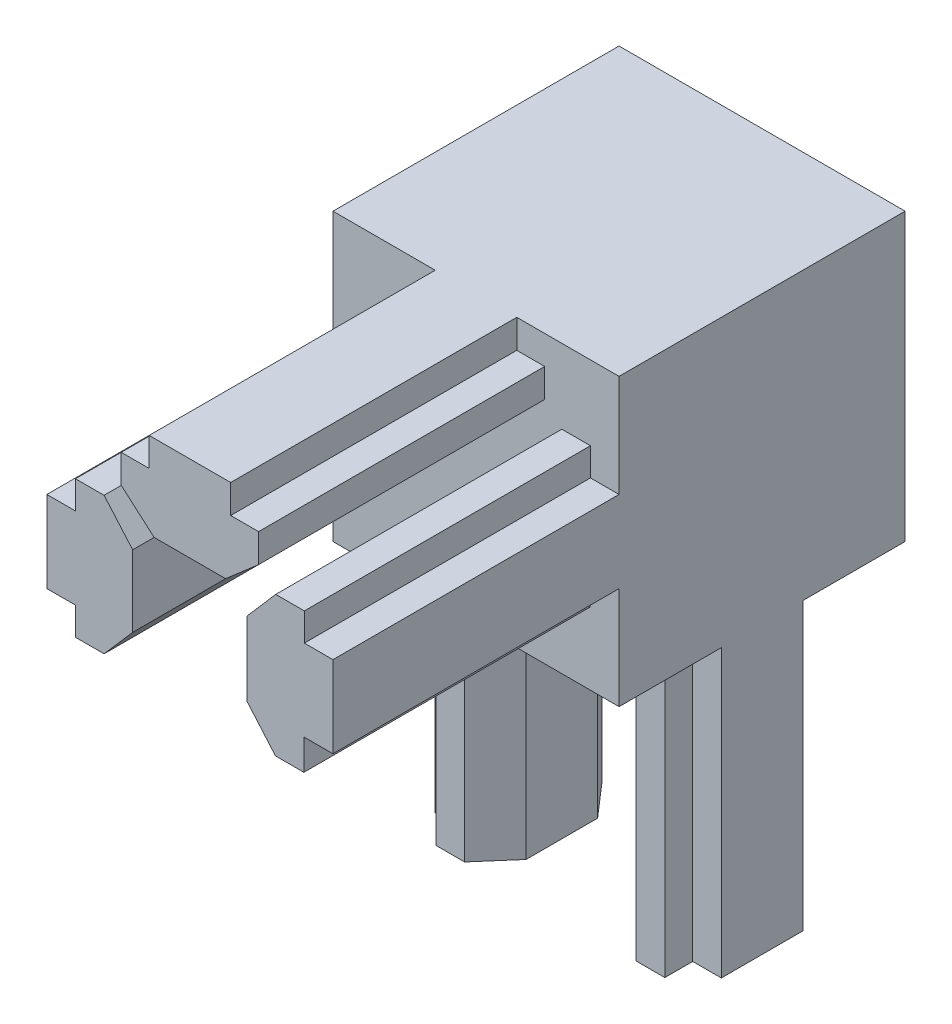
from build123d import *

# Parameters (mm, degrees)
SKETCH1_W           = 20
SKETCH1_H           = 20
BOSS_EXTRUDE1_DEPTH = 20
BOSS_EXTRUDE2_DEPTH = 20
BOSS_EXTRUDE3_DEPTH = 20
BOSS_EXTRUDE4_DEPTH = 20
BOSS_EXTRUDE5_DEPTH = 20


with BuildPart() as part:
    # Sketch1 → Boss-Extrude1 (new body)
    with BuildSketch(Plane.XY):
        Rectangle(SKETCH1_W, SKETCH1_H)
    extrude(amount=BOSS_EXTRUDE1_DEPTH)

    # Sketch2 → Boss-Extrude2 (add)
    with BuildSketch(Plane.XY.offset(20)):
        Polygon((2.85, 10), (2.85, 8), (4.8, 8), (4.8, 6), (2.5, 4), (-2.5, 4), (-4.8, 6), (-4.8, 8), (-2.85, 8), (-2.85, 10), align=None)
    extrude(amount=BOSS_EXTRUDE2_DEPTH)

    # Sketch3 → Boss-Extrude3 (add)
    with BuildSketch(Plane.XY.offset(20)):
        Polygon((-10, 2.85), (-8, 2.85), (-8, 4.8), (-6, 4.8), (-4, 2.5), (-4, -2.5), (-6, -4.8), (-8, -4.8), (-8, -2.85), (-10, -2.85), align=None)
    extrude(amount=BOSS_EXTRUDE3_DEPTH)

    # Sketch4 → Boss-Extrude4 (add)
    with BuildSketch(Plane.XY.offset(20)):
        Polygon((10, 2.85), (8, 2.85), (8, 4.8), (6, 4.8), (4, 2.5), (4, -2.689613267), (5.983673404, -4.989613267), (7.967346808, -4.989613267), (7.967346808, -2.85), (10, -2.85), align=None)
    extrude(amount=BOSS_EXTRUDE4_DEPTH)

    # Sketch5 → Boss-Extrude5 (add)
    with BuildSketch(Plane.XZ.offset(10)):
        Polygon((-10, 12.85), (-8, 12.85), (-8, 14.8), (-6, 14.8), (-4, 12.5), (-4, 7.5), (-6, 5.2), (-8, 5.2), (-8, 7.15), (-10, 7.15), align=None)
        Polygon((10, 12.85), (8, 12.85), (8, 14.8), (6, 14.8), (4, 12.5), (4, 7.5), (6, 5.2), (8, 5.2), (8, 7.15), (10, 7.15), align=None)
        Polygon((-2.85, 0), (2.85, 0), (2.85, 2), (4.8, 2), (4.8, 4), (2.5, 6), (-2.5, 6), (-4.8, 4), (-4.8, 2), (-2.85, 2), align=None)
    extrude(amount=BOSS_EXTRUDE5_DEPTH)


solid = part.part
